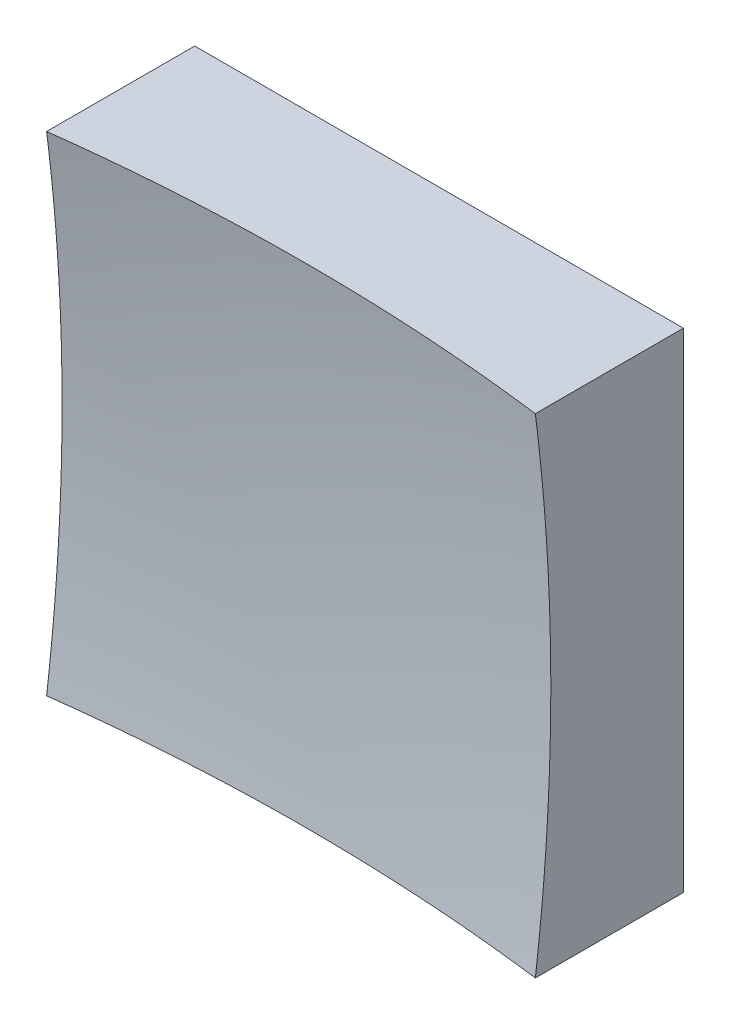
from build123d import *

# Parameters (mm, degrees)
SKETCH_1_W      = 25
SKETCH_1_H      = 25
EXTRUDE_1_DEPTH = 20


with BuildPart() as part:
    # 草图1 → 凸台-拉伸1 (new body)
    with BuildSketch(Plane.XY):
        Rectangle(SKETCH_1_W, SKETCH_1_H)
    extrude(amount=EXTRUDE_1_DEPTH)

    # 草图2 → 切除-旋转2 (revolve, cut)
    with BuildSketch(Plane(origin=(0, 0, 0), x_dir=(1, 0, 0), z_dir=(0, 1, 0))):
        with BuildLine():
            Line((97.484546181, -83.711813537), (0, -83.711813537))
            Line((0, -83.711813537), (0, -6))
            ThreePointArc((0, -6), (62.334506309, -27.805311413), (97.484546181, -83.711813537))
        make_face()
    revolve(axis=Axis((0, 0, 83.711813537), (0, 0, -1)), mode=Mode.SUBTRACT)


solid = part.part
